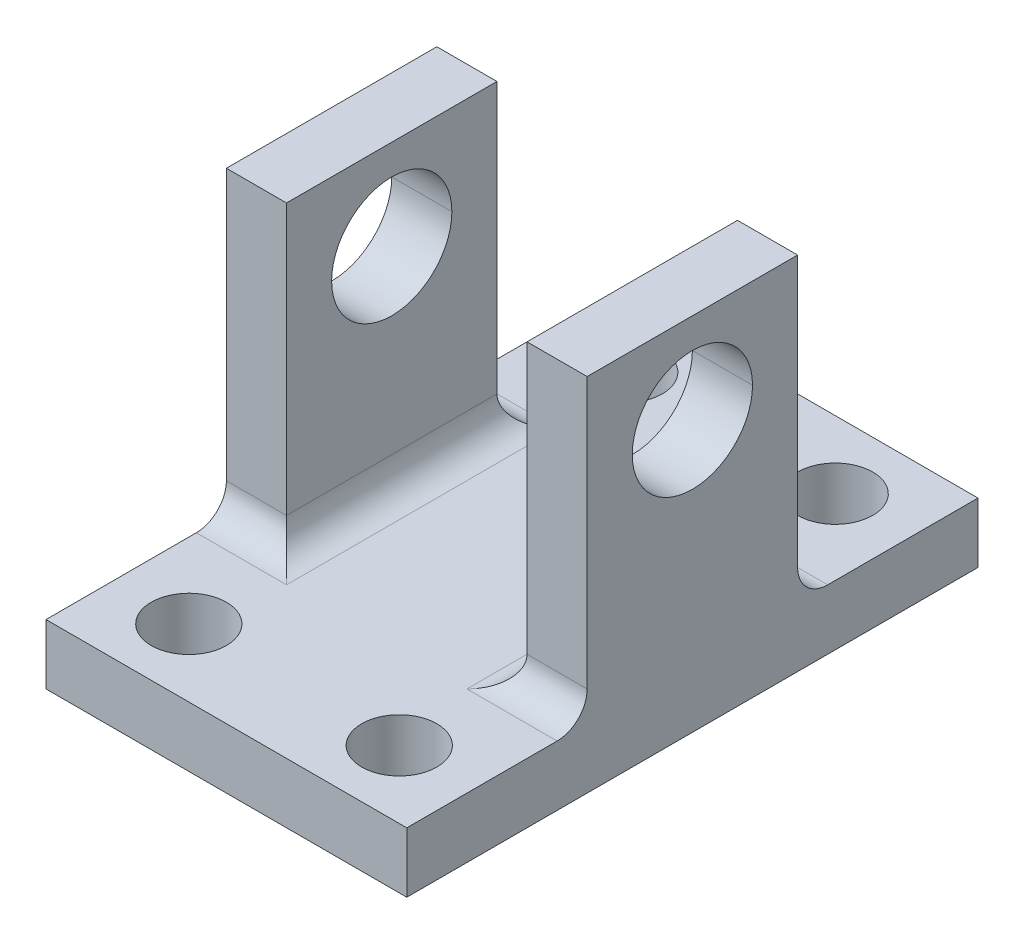
from build123d import *

# Parameters (mm, degrees)
BOSS_EXTRUDE1_DEPTH   = 19
M8_HOLE_DEPTH         = 37.565010598
M8_HOLE_DEPTH_BACK    = 37.565010598
SKETCH2_R             = 4
M5_HOLES_DEPTH        = 37.565010598
M5_HOLES_DEPTH_BACK   = 37.565010598
SKETCH3_R             = 2.5
SKETCH4_W             = 12
SKETCH4_H             = 20
TRIM_DOWN_SIDES_DEPTH = 39.897300678
FILLET3_R             = 2


with BuildPart() as part:
    # Sketch1 → Boss-Extrude1 (new, symmetric)
    with BuildSketch(Plane.XY):
        Polygon((0, 24), (-4, 24), (-4, 4), (-20, 4), (-20, 24), (-24, 24), (-24, 0), (0, 0), align=None)
    extrude(amount=BOSS_EXTRUDE1_DEPTH, both=True)

    # Sketch2 → M8 hole (cut, two sides: drawn at the far end of the back side and taken through both)
    with BuildSketch(Plane.ZY.offset(4).offset(-M8_HOLE_DEPTH_BACK)):
        with Locations((0, 18)):
            Circle(SKETCH2_R)
    extrude(amount=M8_HOLE_DEPTH + M8_HOLE_DEPTH_BACK, mode=Mode.SUBTRACT)

    # Sketch3 → M5 holes (cut, two sides: drawn at the far end of the back side and taken through both)
    with BuildSketch(Plane(origin=(0, 4, 0), x_dir=(1, 0, 0), z_dir=(0, 1, 0)).offset(-M5_HOLES_DEPTH_BACK)):
        with Locations((-19, 14.5)):
            Circle(SKETCH3_R)
        with Locations((-5, 14.5)):
            Circle(SKETCH3_R)
        with Locations((-5, -14.5)):
            Circle(SKETCH3_R)
        with Locations((-19, -14.5)):
            Circle(SKETCH3_R)
    extrude(amount=M5_HOLES_DEPTH + M5_HOLES_DEPTH_BACK, mode=Mode.SUBTRACT)

    # Sketch4 → trim down sides (cut, through all)
    with BuildSketch(Plane.ZY.offset(24)):
        with Locations((-13, 14)):
            Rectangle(SKETCH4_W, SKETCH4_H)
        with Locations((13, 14)):
            Rectangle(SKETCH4_W, SKETCH4_H)
    extrude(amount=-TRIM_DOWN_SIDES_DEPTH, mode=Mode.SUBTRACT)

    # Fillet3
    fillet3_edges = [part.edges().sort_by_distance(p)[0] for p in [
        (-22, 4, -7),
        (-2, 4, -7),
        (-4, 4, 0),
        (-2, 4, 7),
        (-20, 4, 0),
        (-22, 4, 7),
    ]]
    fillet(fillet3_edges, radius=FILLET3_R)


solid = part.part
